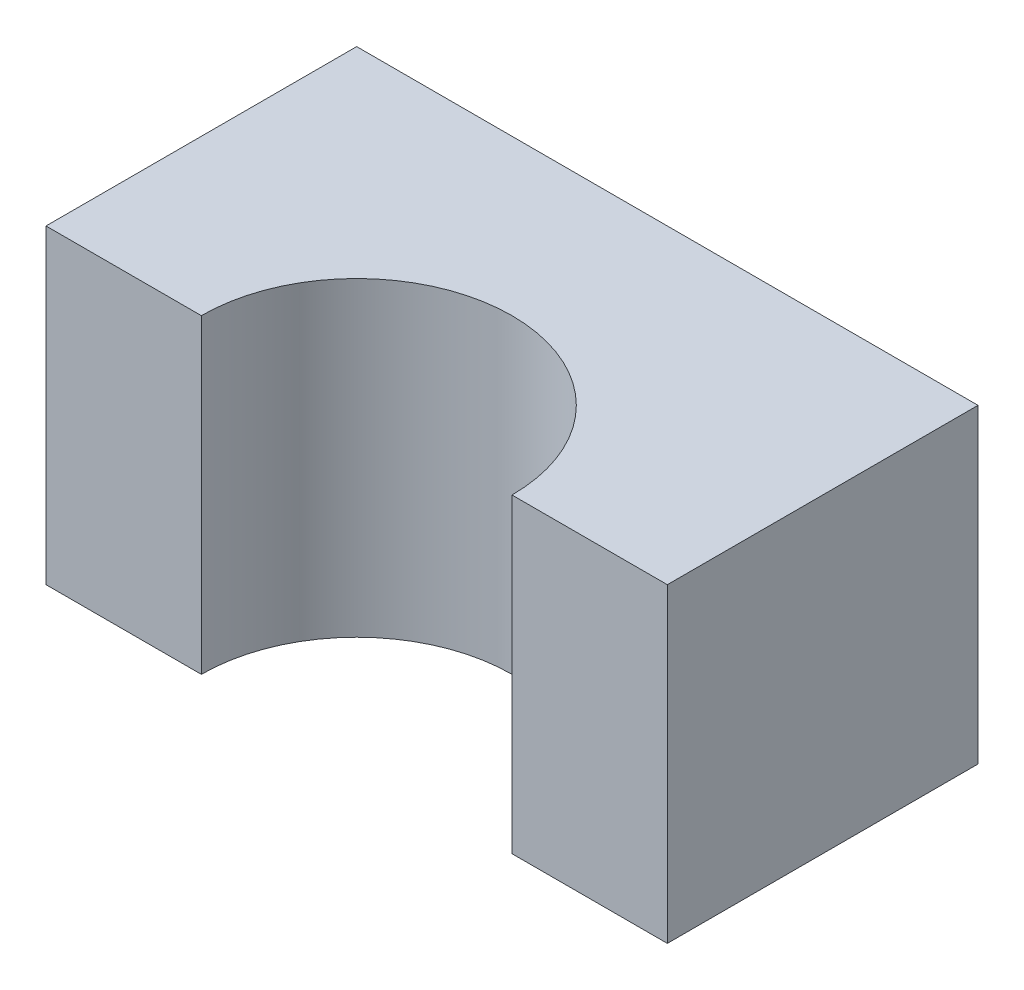
from build123d import *

# Parameters (mm, degrees)
CROQUIS1_W              = 40
CROQUIS1_H              = 20
SALIENTE_EXTRUIR1_DEPTH = 20
CROQUIS2_R              = 10
CORTAR_EXTRUIR1_DEPTH   = 20


with BuildPart() as part:
    # Croquis1 → Saliente-Extruir1 (new body)
    with BuildSketch(Plane(origin=(0, 0, 0), x_dir=(1, 0, 0), z_dir=(0, 1, 0))):
        Rectangle(CROQUIS1_W, CROQUIS1_H)
    extrude(amount=SALIENTE_EXTRUIR1_DEPTH)

    # Croquis2 → Cortar-Extruir1 (cut)
    with BuildSketch(Plane(origin=(0, 20, 0), x_dir=(1, 0, 0), z_dir=(0, 1, 0))):
        with Locations((0, -10)):
            Circle(CROQUIS2_R)
    extrude(amount=-CORTAR_EXTRUIR1_DEPTH, mode=Mode.SUBTRACT)


solid = part.part
